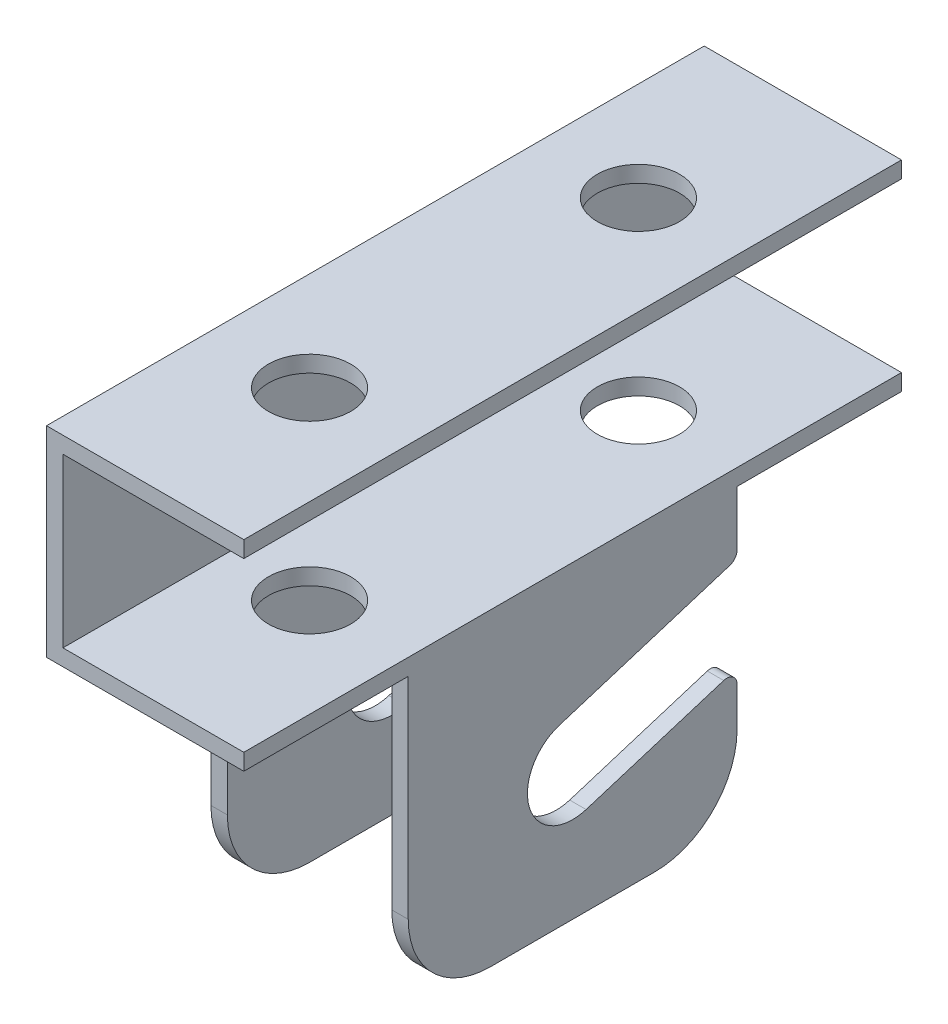
from build123d import *

# Parameters (mm, degrees)
BOSS_EXTRUDE1_DEPTH     = 50.8
SKETCH4_W               = 25.4
SKETCH4_H               = 45.212
CUT_EXTRUDE1_DEPTH      = 1
CUT_EXTRUDE1_DEPTH_BACK = 31.48
CUT_EXTRUDE2_DEPTH      = 1
CUT_EXTRUDE2_DEPTH_BACK = 31.48
FILLET1_R               = 12.7
FILLET2_R               = 1.5875
SKETCH6_R               = 6.35
BOLT_HOLES_DEPTH        = 1
BOLT_HOLES_DEPTH_BACK   = 50.8


with BuildPart() as part:
    # Sketch1 → Boss-Extrude1 (new body, symmetric)
    with BuildSketch(Plane.XY):
        Polygon((0, 0), (0, 76.2), (30.48, 76.2), (30.48, 73.66), (2.54, 73.66), (2.54, 47.752), (30.48, 47.752), (30.48, 0), (27.94, 0), (27.94, 45.212), (2.54, 45.212), (2.54, 0), align=None)
    extrude(amount=BOSS_EXTRUDE1_DEPTH, both=True)

    # Sketch4 → Cut-Extrude1 (cut, two sides)
    with BuildSketch(Plane(origin=(30.48, 0, 0), x_dir=(0, 0, -1), z_dir=(1, 0, 0))) as cut_extrude1_sk:
        with Locations((-38.1, 22.606)):
            Rectangle(SKETCH4_W, SKETCH4_H)
        with Locations((38.1, 22.606)):
            Rectangle(SKETCH4_W, SKETCH4_H)
    extrude(amount=CUT_EXTRUDE1_DEPTH, mode=Mode.SUBTRACT)
    extrude(cut_extrude1_sk.sketch, amount=-CUT_EXTRUDE1_DEPTH_BACK, mode=Mode.SUBTRACT)

    # Sketch5 → Cut-Extrude2 (cut, two sides)
    with BuildSketch(Plane.ZY) as cut_extrude2_sk:
        with BuildLine():
            Line((2.079997498, 26.98812083), (-25.4, 35.56))
            Line((-25.4, 35.56), (-25.4, 20.926124507))
            Line((-25.4, 20.926124507), (-2.079997498, 13.65187917))
            ThreePointArc((-2.079997498, 13.65187917), (6.66812083, 18.240002502), (2.079997498, 26.98812083))
        make_face()
    extrude(amount=CUT_EXTRUDE2_DEPTH, mode=Mode.SUBTRACT)
    extrude(cut_extrude2_sk.sketch, amount=-CUT_EXTRUDE2_DEPTH_BACK, mode=Mode.SUBTRACT)

    # Fillet1
    fillet1_edges = [part.edges().sort_by_distance(p)[0] for p in [
        (1.27, 0, 25.4),
        (29.21, 0, 25.4),
        (1.27, 0, -25.4),
        (29.21, 0, -25.4),
    ]]
    fillet(fillet1_edges, radius=FILLET1_R)

    # Fillet2
    fillet2_edges = [part.edges().sort_by_distance(p)[0] for p in [
        (29.21, 20.926124507, -25.4),
        (29.21, 35.56, -25.4),
        (1.27, 35.56, -25.4),
        (1.27, 20.926124507, -25.4),
    ]]
    fillet(fillet2_edges, radius=FILLET2_R)

    # Sketch6 → BOLT HOLES (cut, two sides)
    with BuildSketch(Plane(origin=(0, 76.2, 0), x_dir=(1, 0, 0), z_dir=(0, 1, 0))) as bolt_holes_sk:
        with Locations((15.24, 25.4)):
            Circle(SKETCH6_R)
        with Locations((15.24, -25.4)):
            Circle(SKETCH6_R)
    extrude(amount=BOLT_HOLES_DEPTH, mode=Mode.SUBTRACT)
    extrude(bolt_holes_sk.sketch, amount=-BOLT_HOLES_DEPTH_BACK, mode=Mode.SUBTRACT)


solid = part.part
